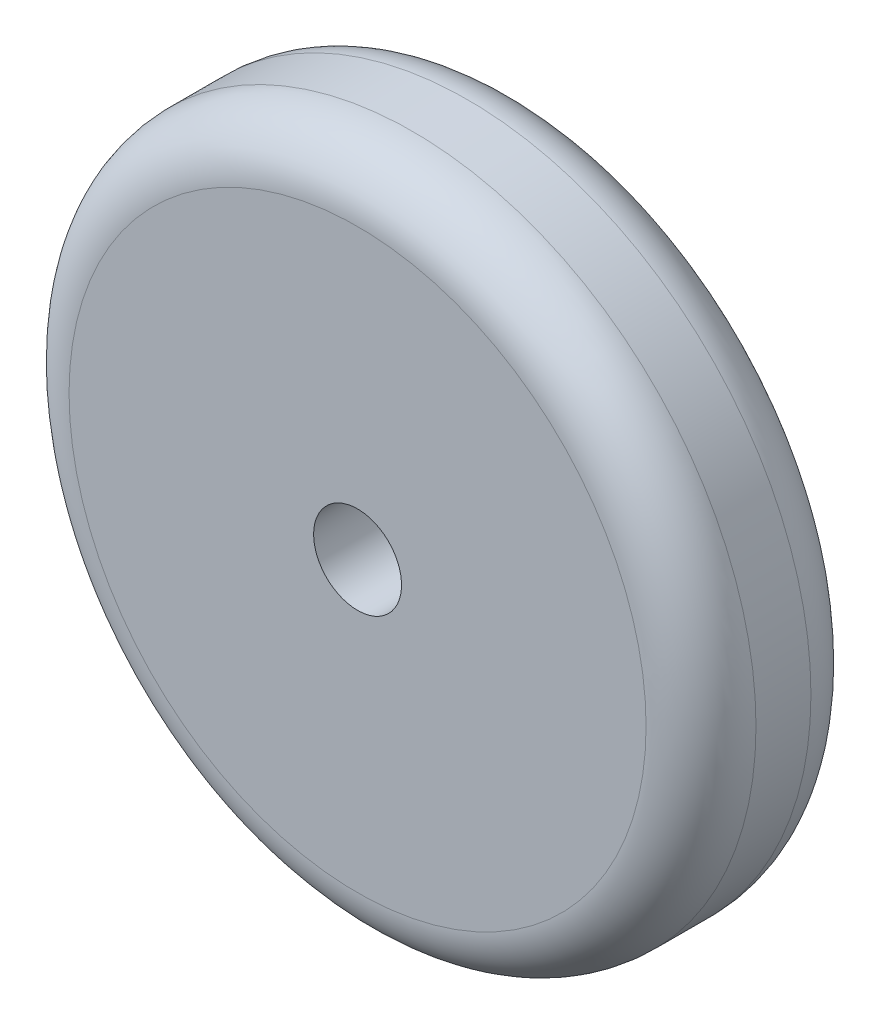
from build123d import *

# Parameters (mm, degrees)
SKETCH_2_R          = 62.5
EXTRUDE_1_DEPTH     = 30
FILLET_1_R          = 10
SKETCH_3_R          = 8
CUT_EXTRUDE_1_DEPTH = 31


with BuildPart() as part:
    # 草图2 → 凸台-拉伸1 (new body)
    with BuildSketch(Plane.XY):
        Circle(SKETCH_2_R)
    extrude(amount=EXTRUDE_1_DEPTH)

    # 圆角1
    fillet_1_edges = [part.edges().sort_by_distance(p)[0] for p in [
        (-62.5, 0, 0),
        (-62.5, 0, 30),
    ]]
    fillet(fillet_1_edges, radius=FILLET_1_R)

    # 草图3 → 切除-拉伸1 (cut, through all)
    with BuildSketch(Plane(origin=(0, 0, 0), x_dir=(-1, 0, 0), z_dir=(0, 0, -1))):
        Circle(SKETCH_3_R)
    extrude(amount=-CUT_EXTRUDE_1_DEPTH, mode=Mode.SUBTRACT)


solid = part.part
